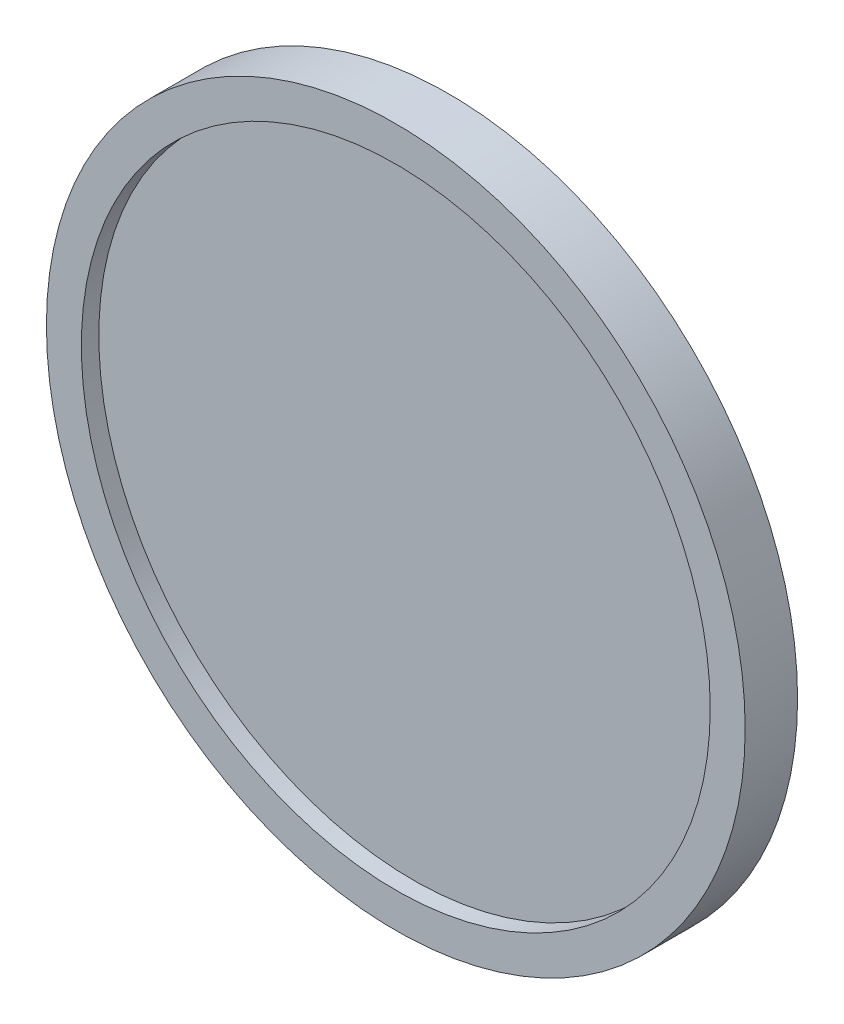
from build123d import *

# Parameters (mm, degrees)
SKETCH_1_R      = 20
EXTRUDE_1_DEPTH = 2
SKETCH_2_R      = 20
SKETCH_2_R_2    = 18
EXTRUDE_2_DEPTH = 1


with BuildPart() as part:
    # 草图1 → 凸台-拉伸1 (new body)
    with BuildSketch(Plane.XY):
        Circle(SKETCH_1_R)
    extrude(amount=EXTRUDE_1_DEPTH)

    # 草图2 → 凸台-拉伸2 (add)
    with BuildSketch(Plane.XY.offset(2)):
        Circle(SKETCH_2_R)
        Circle(SKETCH_2_R_2, mode=Mode.SUBTRACT)
    extrude(amount=EXTRUDE_2_DEPTH)


solid = part.part
